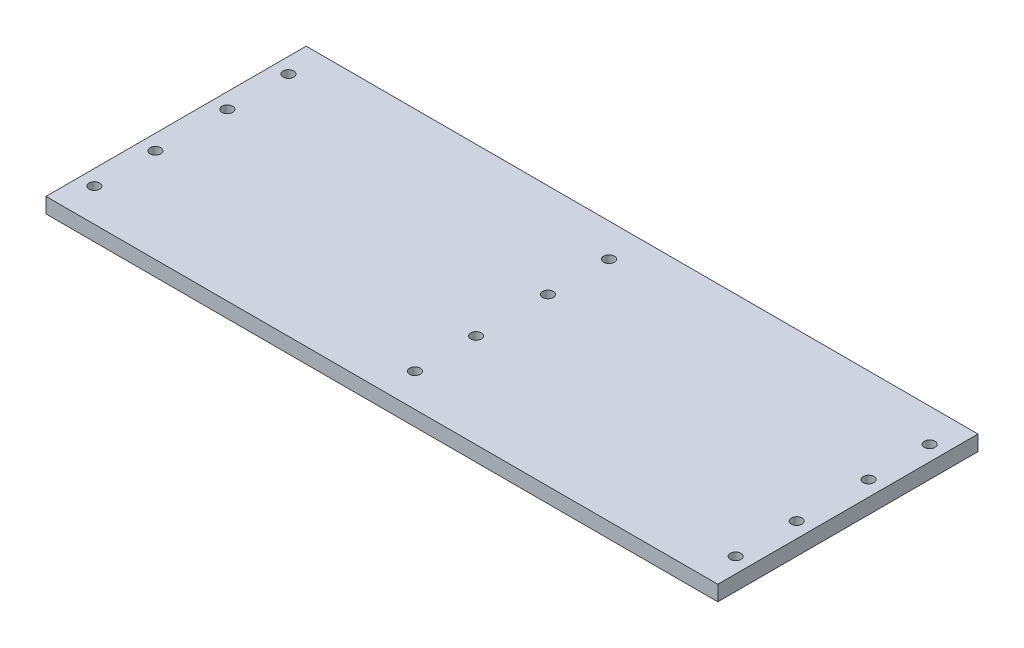
from build123d import *

# Parameters (mm, degrees)
SKETCH_1_W          = 220
SKETCH_1_H          = 85.2
EXTRUDE_1_DEPTH     = 5
SKETCH_2_R          = 1.75
CUT_EXTRUDE_1_DEPTH = 10


with BuildPart() as part:
    # 草图1 → 凸台-拉伸1 (new body)
    with BuildSketch(Plane(origin=(0, 0, 0), x_dir=(1, 0, 0), z_dir=(0, 1, 0))):
        with Locations((44.295012832, 1.717252595)):
            Rectangle(SKETCH_1_W, SKETCH_1_H)
    extrude(amount=EXTRUDE_1_DEPTH)

    # 草图2 → 切除-拉伸1 (cut)
    with BuildSketch(Plane(origin=(0, 5, 0), x_dir=(1, 0, 0), z_dir=(0, 1, 0))):
        with Locations((149.295012832, -30.052747405)):
            Circle(SKETCH_2_R)
        with Locations((149.295012832, -10.052747405)):
            Circle(SKETCH_2_R)
        with Locations((44.295012832, -10.052747405)):
            Circle(SKETCH_2_R)
        with Locations((44.295012832, -30.052747405)):
            Circle(SKETCH_2_R)
        with Locations((44.295012832, 13.487252595)):
            Circle(SKETCH_2_R)
        with Locations((44.295012832, 33.487252595)):
            Circle(SKETCH_2_R)
        with Locations((149.295012832, 13.487252595)):
            Circle(SKETCH_2_R)
        with Locations((149.295012832, 33.487252595)):
            Circle(SKETCH_2_R)
        with Locations((-60.704987168, 33.487252595)):
            Circle(SKETCH_2_R)
        with Locations((-60.704987168, 13.487252595)):
            Circle(SKETCH_2_R)
        with Locations((-60.704987168, -10.052747405)):
            Circle(SKETCH_2_R)
        with Locations((-60.704987168, -30.052747405)):
            Circle(SKETCH_2_R)
    extrude(amount=-CUT_EXTRUDE_1_DEPTH, mode=Mode.SUBTRACT)


solid = part.part
